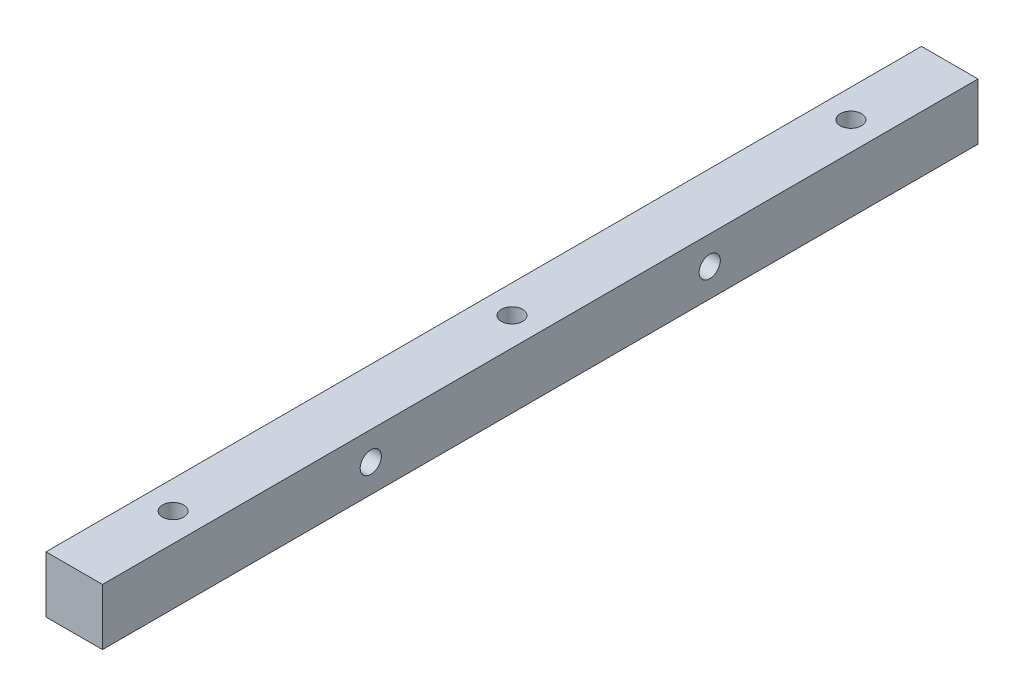
from build123d import *

# Parameters (mm, degrees)
CROQUIS1_W                   = 10
CROQUIS1_H                   = 10
SALIENTE_EXTRUIR1_DEPTH      = 77.5
TALADRO_DE_MARGEN_PARA_M31_D = 3.75
CORTAR_EXTRUIR1_DEPTH        = 3
TALADRO_DE_MARGEN_PARA_M32_D = 3.75
CORTAR_EXTRUIR2_DEPTH        = 3
CORTAR_EXTRUIR3_DEPTH        = 3.2
MATRIZL1_COUNT               = 3
MATRIZL1_PITCH               = 30
MATRIZL1_COL_COUNT           = 2
MATRIZL1_COL_PITCH           = 30


with BuildPart() as part:
    # Croquis1 → Saliente-Extruir1 (new body, symmetric)
    with BuildSketch(Plane.XY):
        Rectangle(CROQUIS1_W, CROQUIS1_H)
    extrude(amount=SALIENTE_EXTRUIR1_DEPTH, both=True)

    # Taladro de margen para M31 (through all)
    with Locations(Plane(origin=(0, 5, 0), x_dir=(1, 0, 0), z_dir=(0, 1, 0))):
        with Locations((0, -60), (0, 0), (0, 60)):
            Hole(TALADRO_DE_MARGEN_PARA_M31_D / 2)

    # Croquis7 → Cortar-Extruir1 (cut)
    with BuildSketch(Plane.XZ.offset(5)):
        Polygon((2.771281292, -58.4), (0, -56.8), (-2.771281292, -58.4), (-2.771281292, -61.6), (0, -63.2), (2.771281292, -61.6), align=None)
        Polygon((2.771281292, -1.6), (2.771281292, 1.6), (0, 3.2), (-2.771281292, 1.6), (-2.771281292, -1.6), (0, -3.2), align=None)
        Polygon((2.771281292, 58.4), (2.771281292, 61.6), (0, 63.2), (-2.771281292, 61.6), (-2.771281292, 58.4), (0, 56.8), align=None)
    extrude(amount=-CORTAR_EXTRUIR1_DEPTH, mode=Mode.SUBTRACT)

    # Taladro de margen para M32 (through all)
    with Locations(Plane.ZY.offset(5)):
        with Locations((-30, 0), (30, 0)):
            Hole(TALADRO_DE_MARGEN_PARA_M32_D / 2)

    # Croquis10 → Cortar-Extruir2 (cut)
    with BuildSketch(Plane.ZY.offset(5)):
        Polygon((-28.4, -2.771281292), (-26.8, 0), (-28.4, 2.771281292), (-31.6, 2.771281292), (-33.2, 0), (-31.6, -2.771281292), align=None)
        Polygon((31.6, -2.771281292), (33.2, 0), (31.6, 2.771281292), (28.4, 2.771281292), (26.8, 0), (28.4, -2.771281292), align=None)
    extrude(amount=-CORTAR_EXTRUIR2_DEPTH, mode=Mode.SUBTRACT)

    # Croquis13 → Taladro de margen para M33 (revolve, cut)
    with BuildSketch(Plane(origin=(-5, 0, -15), x_dir=(0, 0, 1), z_dir=(0, 1, 0))):
        Polygon((0, 0), (0, 7.126613661), (1.875, 6), (1.875, 0), align=None)
    taladro_de_margen_para_m33 = revolve(axis=Axis((-11.35, 0, -15), (1, 0, 0)), mode=Mode.SUBTRACT)

    # Croquis15 → Cortar-Extruir3 (cut)
    with BuildSketch(Plane.ZY):
        Polygon((-18.6, -5), (-11.4, -5), (-11.4, 0), (-13.2, -3.117691454), (-16.8, -3.117691454), (-18.6, 0), align=None)
        Polygon((-16.8, -3.117691454), (-13.2, -3.117691454), (-11.4, 0), (-13.2, 3.117691454), (-16.8, 3.117691454), (-18.6, 0), align=None)
    cortar_extruir3 = extrude(amount=-CORTAR_EXTRUIR3_DEPTH, mode=Mode.SUBTRACT)

    # MatrizL1: Taladro de margen para M33, Cortar-Extruir3 ×3
    with Locations(*[(0, 0, i * MATRIZL1_PITCH) for i in range(1, MATRIZL1_COUNT)]):
        add(taladro_de_margen_para_m33, mode=Mode.SUBTRACT)
        add(cortar_extruir3, mode=Mode.SUBTRACT)

    # MatrizL1 col: Taladro de margen para M33, Cortar-Extruir3 ×2
    with Locations(*[(0, 0, -i * MATRIZL1_COL_PITCH) for i in range(1, MATRIZL1_COL_COUNT)]):
        add(taladro_de_margen_para_m33, mode=Mode.SUBTRACT)
        add(cortar_extruir3, mode=Mode.SUBTRACT)


solid = part.part
